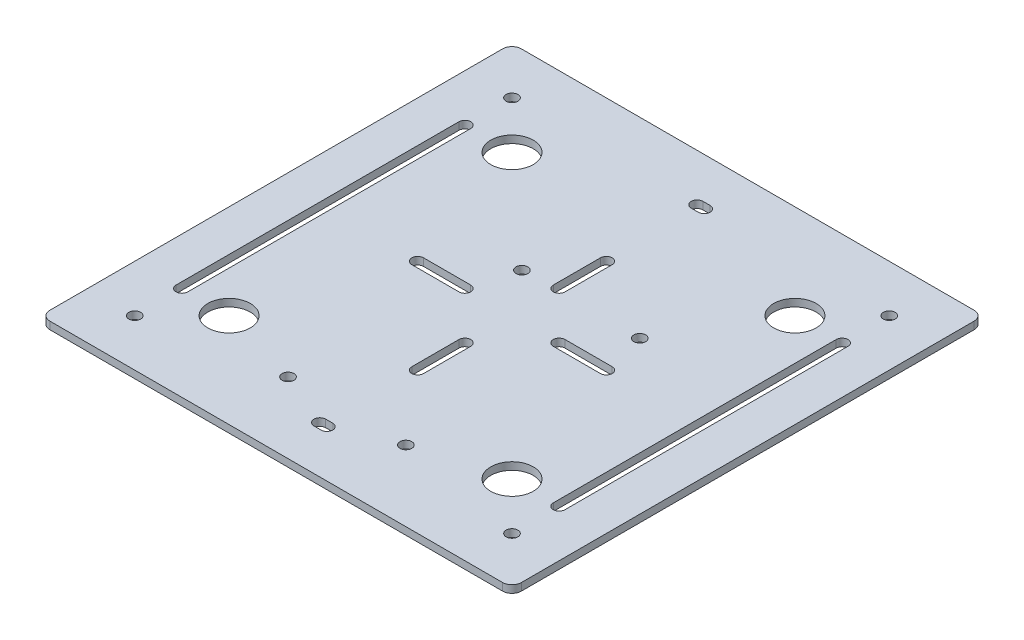
from build123d import *

# Parameters (mm, degrees)
SKETCH2_W                = 100
SKETCH2_H                = 100
BOSS_EXTRUDE1_DEPTH      = 1.5875
CUT_EXTRUDE1_DEPTH       = 5
SKETCH4_R                = 1.25
CUT_EXTRUDE2_DEPTH       = 5
CUT_EXTRUDE4_DEPTH       = 5
CUT_EXTRUDE6_DEPTH       = 5
CIRPATTERN1_COUNT        = 4
CIRPATTERN4_COUNT        = 4
FILLET2_R                = 2
F_2_5MM_DOWEL_HOLE1_D    = 2.5
F_2_5MM_DOWEL_HOLE2_D    = 2.5
F_9_0_9_DIAMETER_HOLE1_D = 9
CIRPATTERN5_COUNT        = 4


with BuildPart() as part:
    # Sketch2 → Boss-Extrude1 (new body)
    with BuildSketch(Plane(origin=(0, 0, 0), x_dir=(1, 0, 0), z_dir=(0, 1, 0))):
        with Locations((50, 50)):
            Rectangle(SKETCH2_W, SKETCH2_H)
    extrude(amount=BOSS_EXTRUDE1_DEPTH)

    # Sketch3 → Cut-Extrude1 (cut)
    with BuildSketch(Plane(origin=(0, 1.5875, 0), x_dir=(1, 0, 0), z_dir=(0, 1, 0))):
        with BuildLine():
            Line((11.25, 80), (11.25, 20))
            ThreePointArc((11.25, 20), (10, 18.75), (8.75, 20))
            Line((8.75, 20), (8.75, 80))
            ThreePointArc((8.75, 80), (10, 81.25), (11.25, 80))
        make_face()
    cut_extrude1 = extrude(amount=-CUT_EXTRUDE1_DEPTH, mode=Mode.SUBTRACT)

    # Sketch4 → Cut-Extrude2 (cut)
    with BuildSketch(Plane(origin=(0, 1.5875, 0), x_dir=(1, 0, 0), z_dir=(0, 1, 0))):
        with Locations((10, 10)):
            Circle(SKETCH4_R)
    cut_extrude2 = extrude(amount=-CUT_EXTRUDE2_DEPTH, mode=Mode.SUBTRACT)

    # Sketch6 → Cut-Extrude4 (cut)
    with BuildSketch(Plane(origin=(0, 1.5875, 0), x_dir=(1, 0, 0), z_dir=(0, 1, 0))):
        with BuildLine():
            Line((49.25, 11.25), (50.75, 11.25))
            ThreePointArc((50.75, 11.25), (52, 10), (50.75, 8.75))
            Line((50.75, 8.75), (49.25, 8.75))
            ThreePointArc((49.25, 8.75), (48, 10), (49.25, 11.25))
        make_face()
    cut_extrude4 = extrude(amount=-CUT_EXTRUDE4_DEPTH, mode=Mode.SUBTRACT)

    # Sketch8 → Cut-Extrude6 (cut)
    with BuildSketch(Plane(origin=(0, 1.5875, 0), x_dir=(1, 0, 0), z_dir=(0, 1, 0))):
        with BuildLine():
            Line((30, 51.25), (40, 51.25))
            ThreePointArc((40, 51.25), (41.25, 50), (40, 48.75))
            Line((40, 48.75), (30, 48.75))
            ThreePointArc((30, 48.75), (28.75, 50), (30, 51.25))
        make_face()
    cut_extrude6 = extrude(amount=-CUT_EXTRUDE6_DEPTH, mode=Mode.SUBTRACT)

    # Mirror3: Cut-Extrude1 across plane
    add(cut_extrude1.mirror(Plane(origin=(50, 0, 0), x_dir=(0, 0, 1), z_dir=(1, 0, 0))), mode=Mode.SUBTRACT)

    # CirPattern1: Cut-Extrude6 ×4 about axis
    cirpattern1_axis = Axis((50, -0.2, -50), (0, 1, 0))
    for i in range(1, CIRPATTERN1_COUNT):
        add(cut_extrude6.rotate(cirpattern1_axis, i * 360 / CIRPATTERN1_COUNT), mode=Mode.SUBTRACT)

    # CirPattern4: Cut-Extrude2 ×4 about axis
    cirpattern4_axis = Axis((50, -0.2, -50), (0, 1, 0))
    for i in range(1, CIRPATTERN4_COUNT):
        add(cut_extrude2.rotate(cirpattern4_axis, i * 360 / CIRPATTERN4_COUNT), mode=Mode.SUBTRACT)

    # Mirror6: Cut-Extrude4 across plane
    add(cut_extrude4.mirror(Plane(origin=(0, 0, -50), x_dir=(1, 0, 0), z_dir=(0, 0, -1))), mode=Mode.SUBTRACT)

    # Fillet2
    fillet2_edges = [part.edges().sort_by_distance(p)[0] for p in [
        (100, 0.79375, 0),
        (0, 0.79375, 0),
        (0, 0.79375, -100),
        (100, 0.79375, -100),
    ]]
    fillet(fillet2_edges, radius=FILLET2_R)

    # Ø2.5mm Dowel Hole1 (through all)
    with Locations(Plane(origin=(0, 1.5875, 0), x_dir=(1, 0, 0), z_dir=(0, 1, 0))):
        with Locations((62.5, 15), (37.5, 15)):
            Hole(F_2_5MM_DOWEL_HOLE1_D / 2)

    # Ø2.5mm Dowel Hole2 (through all)
    with Locations(Plane(origin=(0, 1.5875, 0), x_dir=(1, 0, 0), z_dir=(0, 1, 0))):
        with Locations((42.7, 59.4), (67.7, 59.4)):
            Hole(F_2_5MM_DOWEL_HOLE2_D / 2)

    # Ø9.0 (9) Diameter Hole1 (through all)
    with Locations(Plane(origin=(0, 1.5875, 0), x_dir=(1, 0, 0), z_dir=(0, 1, 0))):
        with Locations((80, 20)):
            f_9_0_9_diameter_hole1 = Hole(F_9_0_9_DIAMETER_HOLE1_D / 2)

    # CirPattern5: Ø9.0 (9) Diameter Hole1 ×4 about axis
    cirpattern5_axis = Axis((50, -0.2, -50), (0, 1, 0))
    for i in range(1, CIRPATTERN5_COUNT):
        add(f_9_0_9_diameter_hole1.rotate(cirpattern5_axis, i * 360 / CIRPATTERN5_COUNT), mode=Mode.SUBTRACT)


solid = part.part
